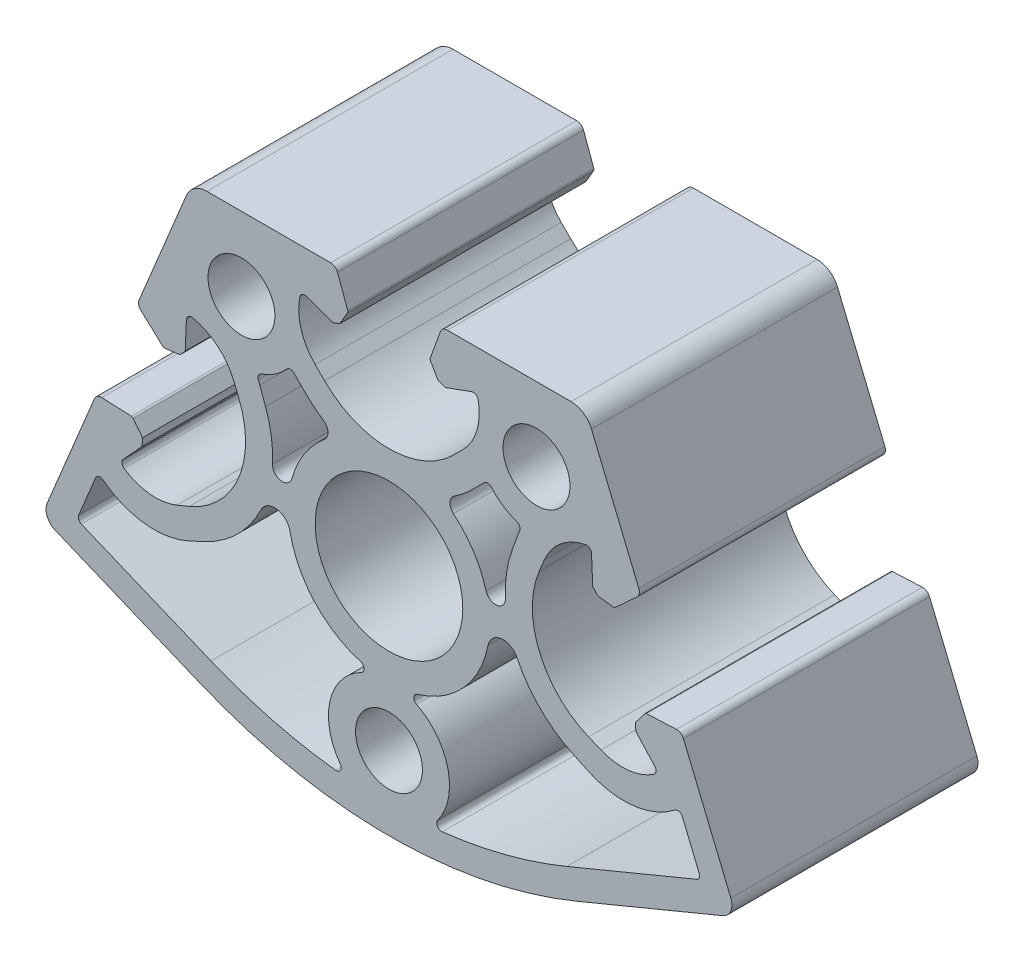
from build123d import *

# Parameters (mm, degrees)
SK_MAIN_EXTRUSION_R   = 3.4
SK_MAIN_EXTRUSION_R_2 = 7.5
MAIN_EXTRUSION_DEPTH  = 25


with BuildPart() as part:
    # Sk Main Extrusion → Main Extrusion (new body)
    with BuildSketch(Plane.XY):
        with BuildLine():
            Line((-29.921765928, -23.953261867), (-34.733312146, -35.569362002))
            ThreePointArc((-34.733312146, -35.569362002), (-34.733312146, -36.717412299), (-33.921517996, -37.529206449))
            Line((-33.921517996, -37.529206449), (-19.134171618, -43.65432587))
            ThreePointArc((-19.134171618, -43.65432587), (0, -47.460349245), (19.134171618, -43.65432587))
            Line((19.134171618, -43.65432587), (33.921517996, -37.529206449))
            ThreePointArc((33.921517996, -37.529206449), (34.733312146, -36.717412299), (34.733312146, -35.569362002))
            Line((34.733312146, -35.569362002), (29.921765928, -23.953261867))
            ThreePointArc((29.921765928, -23.953261867), (29.631830985, -23.607730857), (29.196141739, -23.490988275))
            Line((29.196141739, -23.490988275), (26.181713167, -23.622601069))
            ThreePointArc((26.181713167, -23.622601069), (26.07718086, -23.650610416), (25.994279679, -23.720172767))
            Line((25.994279679, -23.720172767), (25.045750943, -24.956319482))
            Line((25.045750943, -24.956319482), (25.079680803, -25.733441044))
            Line((25.079680803, -25.733441044), (27.004791557, -27.834330774))
            ThreePointArc((27.004791557, -27.834330774), (27.132745088, -28.23040269), (26.916570021, -28.586089924))
            ThreePointArc((26.916570021, -28.586089924), (24.29650429, -29.537651874), (21.538519143, -29.133013131))
            Line((21.538519143, -29.133013131), (20.279746838, -28.61161257))
            ThreePointArc((20.279746838, -28.61161257), (15.273682912, -23.605548644), (15.273682912, -16.525905145))
            Line((15.273682912, -16.525905145), (15.795083472, -15.26713284))
            ThreePointArc((15.795083472, -15.26713284), (17.459150673, -13.030820042), (19.984672826, -11.851009703))
            ThreePointArc((19.984672826, -11.851009703), (20.389040537, -11.949659703), (20.578628865, -12.32020165))
            Line((20.578628865, -12.32020165), (20.702923372, -15.167013893))
            Line((20.702923372, -15.167013893), (21.228439263, -15.740513853))
            Line((21.228439263, -15.740513853), (22.773238089, -15.943890477))
            ThreePointArc((22.773238089, -15.943890477), (22.881046087, -15.934458499), (22.974767189, -15.880348596))
            Line((22.974767189, -15.880348596), (25.199354373, -13.84189001))
            ThreePointArc((25.199354373, -13.84189001), (25.424883722, -13.451261718), (25.385571366, -13.001919434))
            Line((25.385571366, -13.001919434), (20.574025149, -1.385819299))
            ThreePointArc((20.574025149, -1.385819299), (19.747204418, -0.378335324), (18.5, 0))
            Line((18.5, 0), (5.926823816, 0))
            ThreePointArc((5.926823816, 0), (5.496641489, -0.135635967), (5.222054351, -0.493484893))
            Line((5.222054351, -0.493484893), (4.190076845, -3.328819788))
            ThreePointArc((4.190076845, -3.328819788), (4.175951325, -3.436113759), (4.208493649, -3.539324824))
            Line((4.208493649, -3.539324824), (4.987558066, -4.888703976))
            Line((4.987558066, -4.888703976), (5.718509166, -5.154748419))
            Line((5.718509166, -5.154748419), (8.396186179, -4.18015369))
            ThreePointArc((8.396186179, -4.18015369), (8.811074612, -4.213510201), (9.056960151, -4.549345533))
            ThreePointArc((9.056960151, -4.549345533), (8.933433013, -7.334117628), (7.504160339, -9.727315113))
            Line((7.504160339, -9.727315113), (6.540737726, -10.690737726))
            ThreePointArc((6.540737726, -10.690737726), (0, -13.4), (-6.540737726, -10.690737726))
            Line((-6.540737726, -10.690737726), (-7.504160339, -9.727315113))
            ThreePointArc((-7.504160339, -9.727315113), (-8.933433013, -7.334117628), (-9.056960151, -4.549345533))
            ThreePointArc((-9.056960151, -4.549345533), (-8.811074612, -4.213510201), (-8.396186179, -4.18015369))
            Line((-8.396186179, -4.18015369), (-5.718509166, -5.154748419))
            Line((-5.718509166, -5.154748419), (-4.987558066, -4.888703976))
            Line((-4.987558066, -4.888703976), (-4.208493649, -3.539324824))
            ThreePointArc((-4.208493649, -3.539324824), (-4.175951326, -3.436113759), (-4.190076845, -3.328819788))
            Line((-4.190076845, -3.328819788), (-5.222054351, -0.493484893))
            ThreePointArc((-5.222054351, -0.493484893), (-5.496641489, -0.135635967), (-5.926823816, 0))
            Line((-5.926823816, 0), (-18.5, 0))
            ThreePointArc((-18.5, 0), (-19.747204418, -0.378335324), (-20.574025149, -1.385819299))
            Line((-20.574025149, -1.385819299), (-25.385571366, -13.001919433))
            ThreePointArc((-25.385571366, -13.001919433), (-25.424883722, -13.451261718), (-25.199354373, -13.84189001))
            Line((-25.199354373, -13.84189001), (-22.974767189, -15.880348596))
            ThreePointArc((-22.974767189, -15.880348596), (-22.881046087, -15.934458499), (-22.773238089, -15.943890477))
            Line((-22.773238089, -15.943890477), (-21.228439263, -15.740513853))
            Line((-21.228439263, -15.740513853), (-20.702923372, -15.167013893))
            Line((-20.702923372, -15.167013893), (-20.578628865, -12.32020165))
            ThreePointArc((-20.578628865, -12.32020165), (-20.389040538, -11.949659703), (-19.984672826, -11.851009703))
            ThreePointArc((-19.984672826, -11.851009703), (-17.459150673, -13.030820042), (-15.795083472, -15.26713284))
            Line((-15.795083472, -15.26713284), (-15.273682912, -16.525905145))
            ThreePointArc((-15.273682912, -16.525905145), (-15.273682912, -23.605548644), (-20.279746838, -28.61161257))
            Line((-20.279746838, -28.61161257), (-21.538519143, -29.133013131))
            ThreePointArc((-21.538519143, -29.133013131), (-24.29650429, -29.537651873), (-26.916570021, -28.586089924))
            ThreePointArc((-26.916570021, -28.586089924), (-27.132745088, -28.23040269), (-27.004791556, -27.834330774))
            Line((-27.004791556, -27.834330774), (-25.079680803, -25.733441043))
            Line((-25.079680803, -25.733441043), (-25.045750943, -24.956319482))
            Line((-25.045750943, -24.956319482), (-25.994279679, -23.720172767))
            ThreePointArc((-25.994279679, -23.720172767), (-26.07718086, -23.650610416), (-26.181713167, -23.622601069))
            Line((-26.181713167, -23.622601069), (-29.196141738, -23.490988275))
            ThreePointArc((-29.196141738, -23.490988275), (-29.631830985, -23.607730857), (-29.921765928, -23.953261867))
        make_face()
        with Locations((0, -39.960349245)):
            Circle(SK_MAIN_EXTRUSION_R, mode=Mode.SUBTRACT)
        with Locations((0, -23.730174622)):
            Circle(SK_MAIN_EXTRUSION_R_2, mode=Mode.SUBTRACT)
        with Locations((-14.988660216, -7.5)):
            Circle(SK_MAIN_EXTRUSION_R, mode=Mode.SUBTRACT)
        with Locations((14.988660216, -7.5)):
            Circle(SK_MAIN_EXTRUSION_R, mode=Mode.SUBTRACT)
        with BuildLine():
            Line((9.625052301, -11.595510447), (8.485281374, -12.735281374))
            ThreePointArc((8.485281374, -12.735281374), (7.599692811, -13.536800804), (6.63880921, -14.246309933))
            ThreePointArc((6.63880921, -14.246309933), (6.193483107, -15.025693247), (6.552750572, -15.848299215))
            ThreePointArc((6.552750572, -15.848299215), (8.602818108, -18.157561177), (9.872094264, -20.972593282))
            ThreePointArc((9.872094264, -20.972593282), (10.995270193, -21.690670711), (11.83402104, -20.654496798))
            ThreePointArc((11.83402104, -20.654496798), (11.954456959, -18.271534582), (12.543977902, -15.959505431))
            Line((12.543977902, -15.959505431), (13.124776039, -14.364646966))
            ThreePointArc((13.124776039, -14.364646966), (13.19808723, -14.170765643), (13.276131923, -13.978740842))
            ThreePointArc((13.276131923, -13.978740842), (13.271861833, -13.581035849), (12.978684291, -13.312271224))
            ThreePointArc((12.978684291, -13.312271224), (11.572027401, -12.613621046), (10.388204408, -11.581458852))
            ThreePointArc((10.388204408, -11.581458852), (10.027699552, -11.413467489), (9.658642627, -11.561730214))
            ThreePointArc((9.658642627, -11.561730214), (9.641871269, -11.578644002), (9.625052301, -11.595510447))
        make_face(mode=Mode.SUBTRACT)
        with BuildLine():
            Line((-13.124776039, -14.364646966), (-12.543977902, -15.959505431))
            ThreePointArc((-12.543977902, -15.959505431), (-11.954456959, -18.271534582), (-11.83402104, -20.654496798))
            ThreePointArc((-11.83402104, -20.654496798), (-10.995270193, -21.690670711), (-9.872094264, -20.972593282))
            ThreePointArc((-9.872094264, -20.972593282), (-8.602818108, -18.157561177), (-6.552750572, -15.848299215))
            ThreePointArc((-6.552750572, -15.848299215), (-6.193483107, -15.025693247), (-6.63880921, -14.246309933))
            ThreePointArc((-6.63880921, -14.246309933), (-7.599692811, -13.536800804), (-8.485281374, -12.735281374))
            Line((-8.485281374, -12.735281374), (-9.625052301, -11.595510447))
            ThreePointArc((-9.625052301, -11.595510447), (-9.641871269, -11.578644002), (-9.658642627, -11.561730214))
            ThreePointArc((-9.658642627, -11.561730214), (-10.027699552, -11.413467489), (-10.388204408, -11.581458852))
            ThreePointArc((-10.388204408, -11.581458852), (-11.572027401, -12.613621046), (-12.978684291, -13.312271224))
            ThreePointArc((-12.978684291, -13.312271224), (-13.271861833, -13.581035849), (-13.276131923, -13.978740842))
            ThreePointArc((-13.276131923, -13.978740842), (-13.19808723, -14.170765643), (-13.124776039, -14.364646966))
        make_face(mode=Mode.SUBTRACT)
        with BuildLine():
            Line((-18.750058994, -30.942310571), (-20.28848053, -31.659359506))
            ThreePointArc((-20.28848053, -31.659359506), (-24.804964653, -32.39723186), (-29.043770666, -30.67223678))
            ThreePointArc((-29.043770666, -30.67223678), (-29.478516897, -30.583656264), (-29.81254537, -30.875676422))
            Line((-29.81254537, -30.875676422), (-31.522947425, -35.004952259))
            ThreePointArc((-31.522947425, -35.004952259), (-31.522947425, -35.387635691), (-31.252349375, -35.658233741))
            Line((-31.252349375, -35.658233741), (-18.081792179, -41.113657156))
            ThreePointArc((-18.081792179, -41.113657156), (-11.861595522, -43.197260505), (-5.412768699, -44.399292938))
            ThreePointArc((-5.412768699, -44.399292938), (-4.922960585, -44.153418508), (-4.952822248, -43.60617587))
            ThreePointArc((-4.952822248, -43.60617587), (-5.986356997, -38.551083511), (-2.806269936, -34.487932133))
            ThreePointArc((-2.806269936, -34.487932133), (-2.536621736, -33.996170054), (-2.893286059, -33.563352938))
            ThreePointArc((-2.893286059, -33.563352938), (-7.587209558, -30.621963295), (-10.065202734, -25.66774886))
            ThreePointArc((-10.065202734, -25.66774886), (-11.400197121, -24.411013995), (-13.01306014, -25.282945998))
            ThreePointArc((-13.01306014, -25.282945998), (-15.392286163, -28.608613464), (-18.750058994, -30.942310571))
        make_face(mode=Mode.SUBTRACT)
        with BuildLine():
            Line((18.081792179, -41.113657156), (31.252349375, -35.658233741))
            ThreePointArc((31.252349375, -35.658233741), (31.522947425, -35.387635691), (31.522947425, -35.004952259))
            Line((31.522947425, -35.004952259), (29.81254537, -30.875676422))
            ThreePointArc((29.81254537, -30.875676422), (29.478516897, -30.583656264), (29.043770666, -30.67223678))
            ThreePointArc((29.043770666, -30.67223678), (24.804964653, -32.39723186), (20.28848053, -31.659359506))
            Line((20.28848053, -31.659359506), (18.750058994, -30.942310571))
            ThreePointArc((18.750058994, -30.942310571), (15.392286163, -28.608613464), (13.01306014, -25.282945998))
            ThreePointArc((13.01306014, -25.282945998), (11.400197121, -24.411013995), (10.065202734, -25.66774886))
            ThreePointArc((10.065202734, -25.66774886), (7.587209558, -30.621963295), (2.893286059, -33.563352938))
            ThreePointArc((2.893286059, -33.563352938), (2.536621736, -33.996170054), (2.806269936, -34.487932133))
            ThreePointArc((2.806269936, -34.487932133), (5.986356997, -38.551083511), (4.952822248, -43.60617587))
            ThreePointArc((4.952822248, -43.60617587), (4.922960585, -44.153418508), (5.412768699, -44.399292938))
            ThreePointArc((5.412768699, -44.399292938), (11.861595522, -43.197260505), (18.081792179, -41.113657156))
        make_face(mode=Mode.SUBTRACT)
    extrude(amount=-MAIN_EXTRUSION_DEPTH)


solid = part.part
